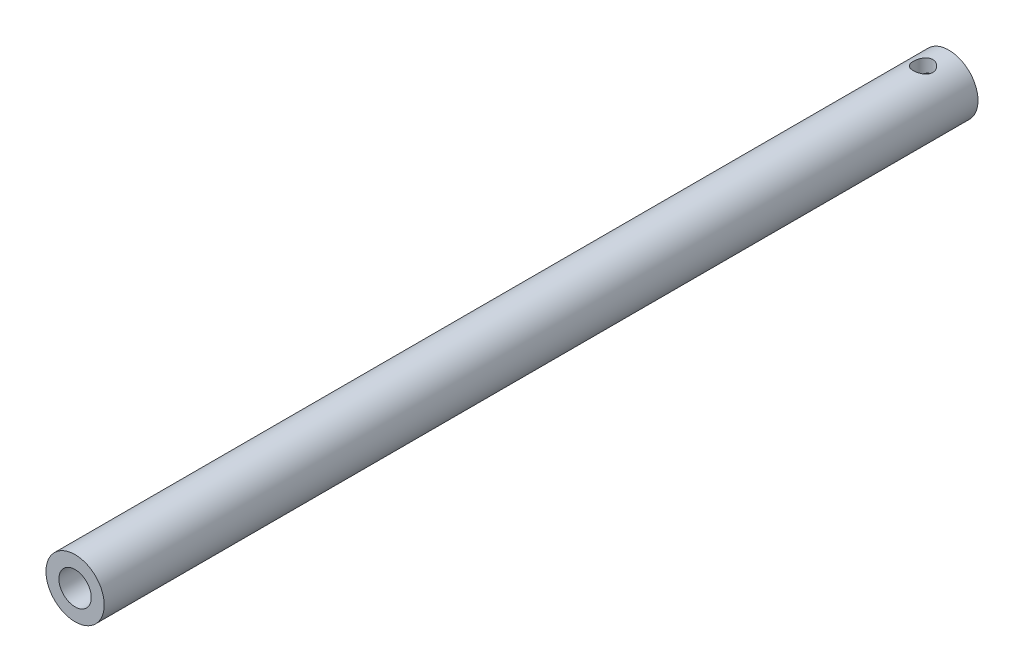
from build123d import *

# Parameters (mm, degrees)
SKETCH1_R               = 9
SKETCH1_R_2             = 5
BOSS_EXTRUDE1_DEPTH     = 270
SKETCH2_R               = 3
CUT_EXTRUDE1_DEPTH      = 10
CUT_EXTRUDE1_DEPTH_BACK = 10


with BuildPart() as part:
    # Sketch1 → Boss-Extrude1 (new body)
    with BuildSketch(Plane.XY):
        Circle(SKETCH1_R)
        Circle(SKETCH1_R_2, mode=Mode.SUBTRACT)
    extrude(amount=BOSS_EXTRUDE1_DEPTH)

    # Sketch2 → Cut-Extrude1 (cut, two sides)
    with BuildSketch(Plane(origin=(0, 0, 0), x_dir=(1, 0, 0), z_dir=(0, 1, 0))) as cut_extrude1_sk:
        with Locations((0, -8)):
            Circle(SKETCH2_R)
    extrude(amount=CUT_EXTRUDE1_DEPTH, mode=Mode.SUBTRACT)
    extrude(cut_extrude1_sk.sketch, amount=-CUT_EXTRUDE1_DEPTH_BACK, mode=Mode.SUBTRACT)


solid = part.part
